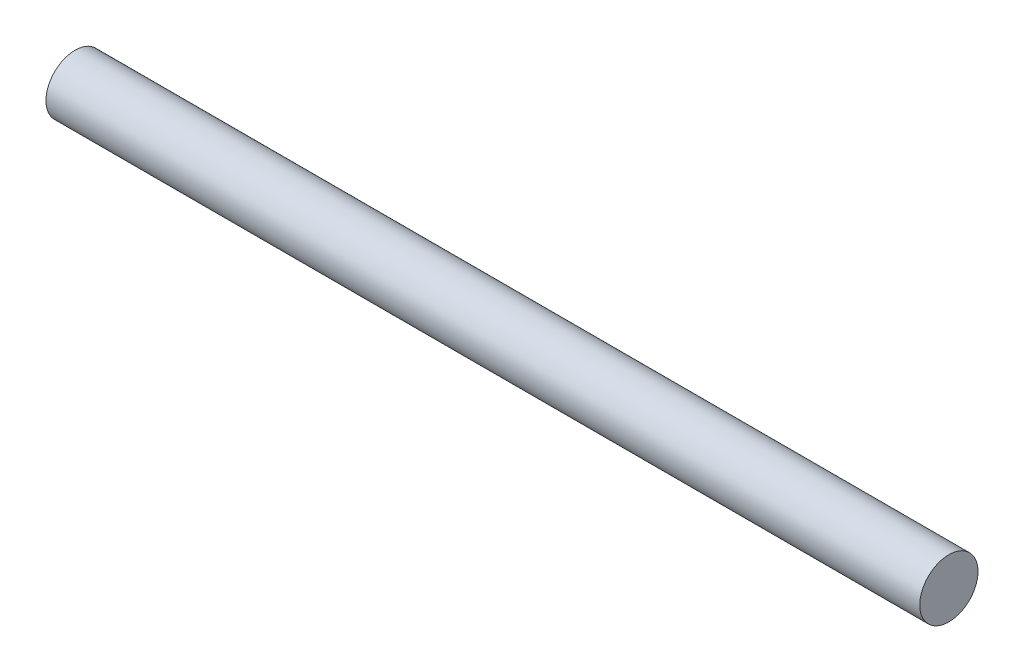
from build123d import *

# Parameters (mm, degrees)
CROQUIS1_R              = 4
SALIENTE_EXTRUIR1_DEPTH = 120


with BuildPart() as part:
    # Croquis1 → Saliente-Extruir1 (new body)
    with BuildSketch(Plane(origin=(0, 0, 0), x_dir=(0, 0, -1), z_dir=(1, 0, 0))):
        Circle(CROQUIS1_R)
    extrude(amount=SALIENTE_EXTRUIR1_DEPTH)


solid = part.part
